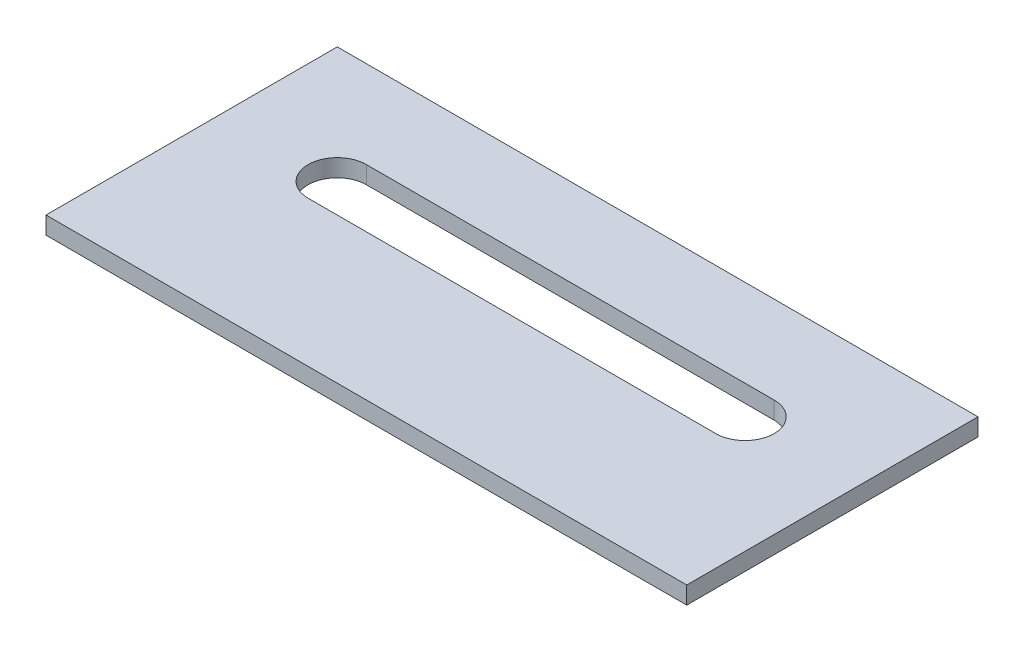
from build123d import *

# Parameters (mm, degrees)
IZIM1_W                     = 110
IZIM1_H                     = 50
Y_KSEKLIK_EKSTR_ZYON1_DEPTH = 3


with BuildPart() as part:
    # Çizim1 → Yükseklik-Ekstrüzyon1 (new body)
    with BuildSketch(Plane(origin=(0, 0, 0), x_dir=(1, 0, 0), z_dir=(0, 1, 0))):
        with Locations((55, -25)):
            Rectangle(IZIM1_W, IZIM1_H)
        with BuildLine():
            Line((20, -15), (90, -15))
            ThreePointArc((90, -15), (95, -20), (90, -25))
            Line((90, -25), (20, -25))
            ThreePointArc((20, -25), (15, -20), (20, -15))
        make_face(mode=Mode.SUBTRACT)
    extrude(amount=Y_KSEKLIK_EKSTR_ZYON1_DEPTH)


solid = part.part
